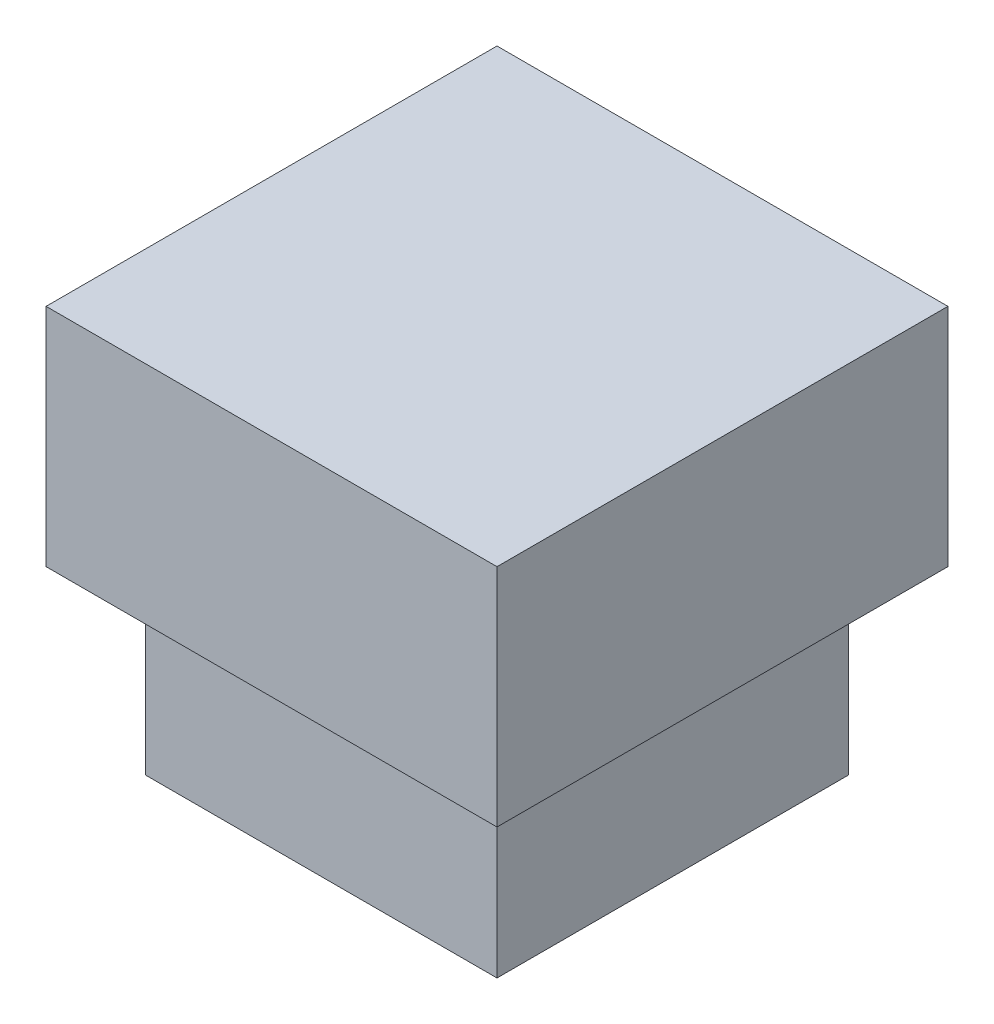
from build123d import *

# Parameters (mm, degrees)
SKETCH_1_W      = 3.9
SKETCH_1_H      = 3.9
EXTRUDE_1_DEPTH = 2
SKETCH_2_W      = 5
SKETCH_2_H      = 5
EXTRUDE_2_DEPTH = 2.5


with BuildPart() as part:
    # Эскиз1 → Бобышка-Вытянуть1 (new body)
    with BuildSketch(Plane(origin=(0, 0, 0), x_dir=(1, 0, 0), z_dir=(0, 1, 0))):
        Rectangle(SKETCH_1_W, SKETCH_1_H)
    extrude(amount=EXTRUDE_1_DEPTH)

    # Эскиз2 → Бобышка-Вытянуть2 (add)
    with BuildSketch(Plane(origin=(0, 2, 0), x_dir=(1, 0, 0), z_dir=(0, 1, 0))):
        Rectangle(SKETCH_2_W, SKETCH_2_H)
    extrude(amount=EXTRUDE_2_DEPTH)


solid = part.part
